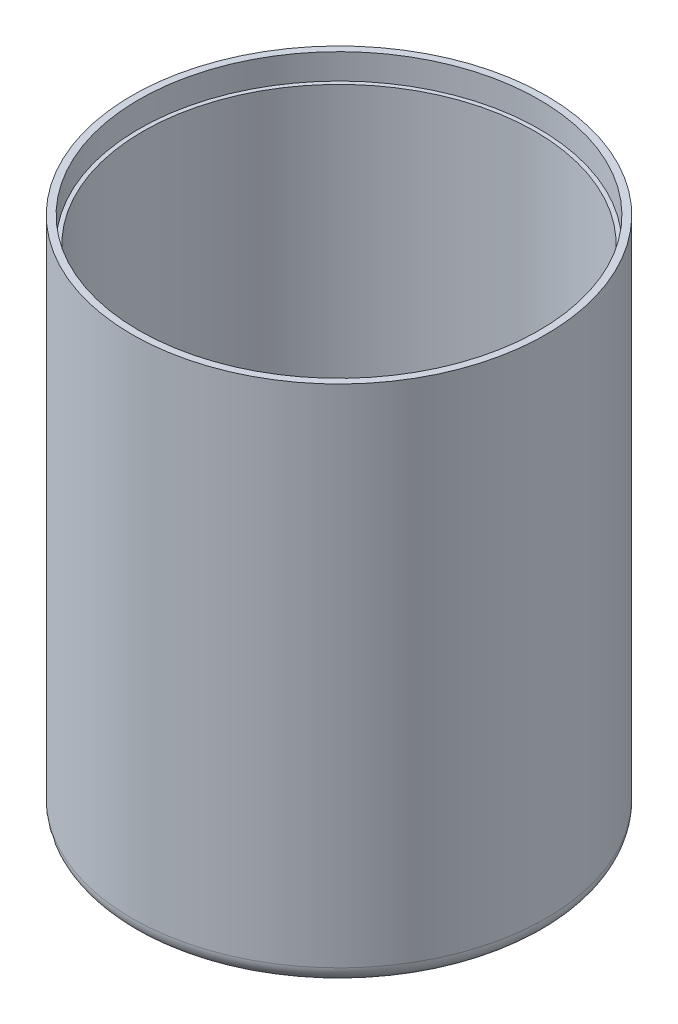
from build123d import *

# Parameters (mm, degrees)
SKETCH_8_R          = 1
CUT_EXTRUDE_1_DEPTH = 31.8
SKETCH_9_W          = 0.43
SKETCH_9_H          = 0.4
HOLE_WIZARD_M3_2_D  = 2.5
SKETCH_13_R         = 11.79
CUT_EXTRUDE_2_DEPTH = 1.5
FILLET_1_R          = 1


with BuildPart() as part:
    # 草图3 → 旋转-薄壁1 (revolve)
    with BuildSketch(Plane.XY):
        Polygon((3.225, -1.7), (3.225, 0), (12.2, 0), (12.2, 30.8), (11.55, 30.8), (11.55, 0.65), (2.575, 0.65), (2.575, -1.7), align=None)
    revolve(axis=Axis((0, -2.280125191, 0), (0, 1, 0)))

    # 草图8 → 切除-拉伸1 (cut, through all)
    with BuildSketch(Plane.XZ):
        with Locations((-8.5, 0)):
            Circle(SKETCH_8_R)
        with Locations((8.5, 0)):
            Circle(SKETCH_8_R)
    extrude(amount=-CUT_EXTRUDE_1_DEPTH, mode=Mode.SUBTRACT)

    # 草图9 → 旋转-薄壁2 (revolve)
    with BuildSketch(Plane.XY):
        with Locations((-9.715, 0.85)):
            Rectangle(SKETCH_9_W, SKETCH_9_H)
    revolve(axis=Axis((-8.5, 2.007130547, 0), (0, -1, 0)))

    # M3 螺纹孔2 (through all)
    with Locations(Plane(origin=(0, 0, 0), x_dir=(-1, 0, 0), z_dir=(0, -1, 0))):
        with Locations((8.5, 0), (-8.5, 0)):
            Hole(HOLE_WIZARD_M3_2_D / 2)

    # 草图13 → 切除-拉伸2 (cut)
    with BuildSketch(Plane(origin=(0, 30.8, 0), x_dir=(1, 0, 0), z_dir=(0, 1, 0))):
        Circle(SKETCH_13_R)
    extrude(amount=-CUT_EXTRUDE_2_DEPTH, mode=Mode.SUBTRACT)

    # 圆角1
    fillet_1_edges = [part.edges().sort_by_distance(p)[0] for p in [
        (-12.2, 0, 0),
    ]]
    fillet(fillet_1_edges, radius=FILLET_1_R)


solid = part.part
